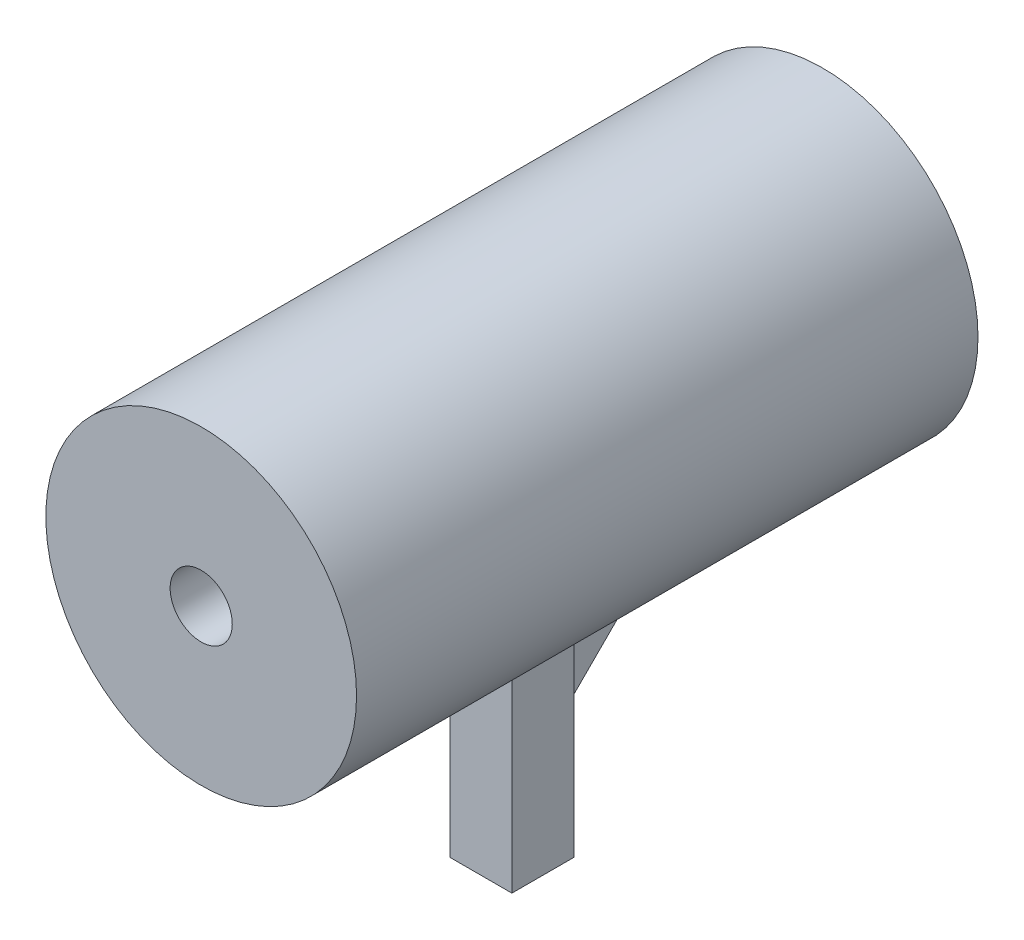
from build123d import *

# Parameters (mm, degrees)
ESQUISSE1_R             = 5
ESQUISSE1_R_2           = 1
BOSS_EXTRU_1_DEPTH      = 10
BOSS_EXTRU_1_DEPTH_BACK = 10
ESQUISSE3_W             = 2
ESQUISSE3_H             = 2
BOSS_EXTRU_2_DEPTH      = 10
BOSS_EXTRU_3_DEPTH      = 0.5
BOSS_EXTRU_3_DEPTH_BACK = 0.5


with BuildPart() as part:
    # Esquisse1 → Boss.-Extru.1 (new body, two sides)
    with BuildSketch(Plane.XY) as boss_extru_1_sk:
        Circle(ESQUISSE1_R)
        Circle(ESQUISSE1_R_2, mode=Mode.SUBTRACT)
    extrude(amount=BOSS_EXTRU_1_DEPTH)
    extrude(boss_extru_1_sk.sketch, amount=-BOSS_EXTRU_1_DEPTH_BACK)

    # Esquisse3 → Boss.-Extru.2 (add)
    with BuildSketch(Plane(origin=(0, -2, 0), x_dir=(1, 0, 0), z_dir=(0, 1, 0))):
        Rectangle(ESQUISSE3_W, ESQUISSE3_H)
    extrude(amount=-BOSS_EXTRU_2_DEPTH)

    # Esquisse4 → Boss.-Extru.3 (add, two sides)
    with BuildSketch(Plane(origin=(0, 0, 0), x_dir=(0, 0, -1), z_dir=(1, 0, 0))) as boss_extru_3_sk:
        Polygon((1, -8.449489743), (4.550510257, -4.898979486), (1, -4.898979486), align=None)
    extrude(amount=BOSS_EXTRU_3_DEPTH)
    extrude(boss_extru_3_sk.sketch, amount=-BOSS_EXTRU_3_DEPTH_BACK)


solid = part.part
